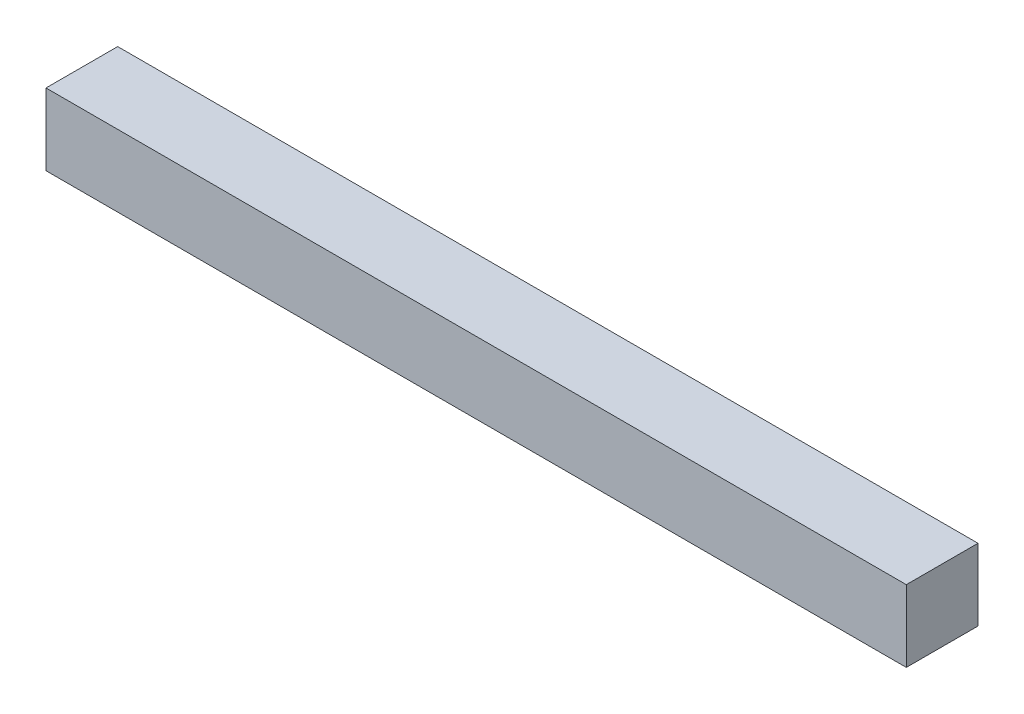
from build123d import *

# Parameters (mm, degrees)
SKETCH1_W           = 25.4
SKETCH1_H           = 25.4
BOSS_EXTRUDE1_DEPTH = 304.8


with BuildPart() as part:
    # Sketch1 → Boss-Extrude1 (new body)
    with BuildSketch(Plane(origin=(0, 0, 0), x_dir=(0, 0, -1), z_dir=(1, 0, 0))):
        with Locations((-12.7, 12.7)):
            Rectangle(SKETCH1_W, SKETCH1_H)
    extrude(amount=BOSS_EXTRUDE1_DEPTH)


solid = part.part
